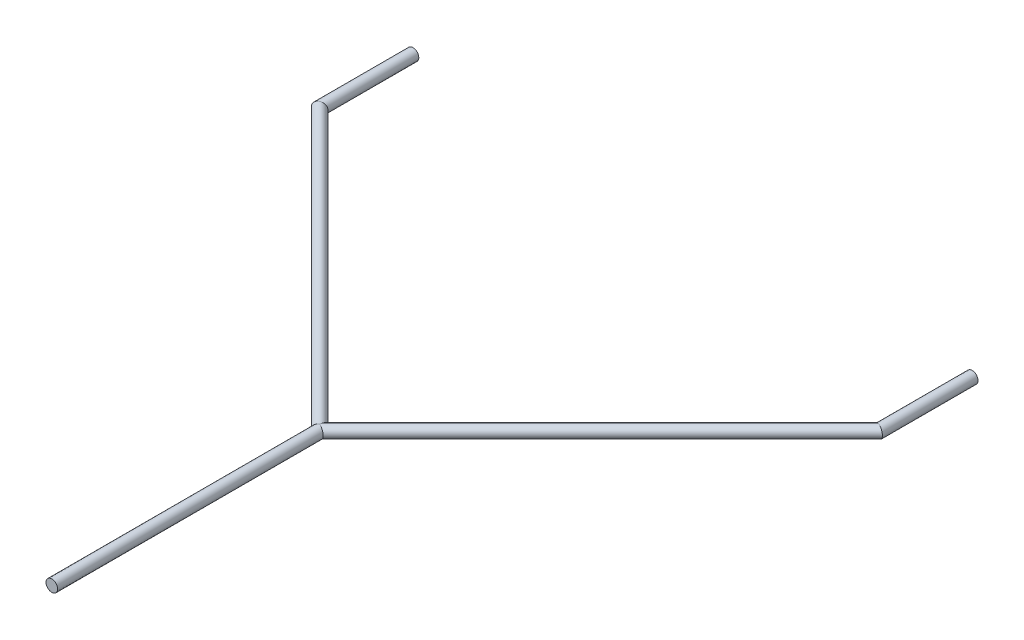
from build123d import *

# Parameters (mm, degrees)
SKETCH2_R = 1.5875
SKETCH3_R = 1.5875


with BuildPart() as part:
    # Sweep1: sweep along a path in Sketch1
    with BuildLine(Plane(origin=(0, 0, 0), x_dir=(1, 0, 0), z_dir=(0, 1, 0))) as sweep1_path:
        Line((0, 0), (0, 73.025))
        Line((0, 73.025), (76.2, 149.225))
        Line((76.2, 149.225), (76.2, 174.625))
    # Sketch2 → Sweep1 (sweep)
    with BuildSketch(Plane.XY):
        Circle(SKETCH2_R)
    sweep(path=sweep1_path.line, transition=Transition.RIGHT)

    # Sweep4: sweep along a path in Sketch4
    with BuildLine(Plane(origin=(0, 0, 0), x_dir=(1, 0, 0), z_dir=(0, 1, 0))) as sweep4_path:
        Line((-76.2, 174.625), (-76.2, 149.225))
        Line((-76.2, 149.225), (0, 73.025))
    # Sketch3 → Sweep4 (sweep)
    with BuildSketch(Plane(origin=(-76.2, 0, -174.625), x_dir=(1, 0, 0), z_dir=(0, 0, 1))):
        Circle(SKETCH3_R)
    sweep(path=sweep4_path.line, transition=Transition.RIGHT)


solid = part.part
